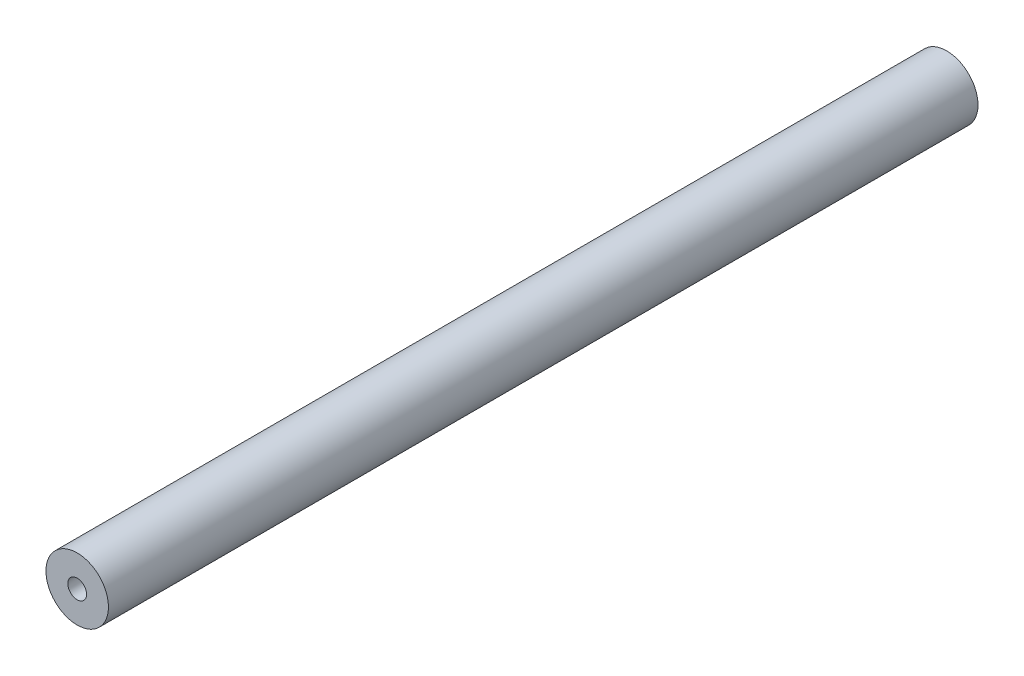
from build123d import *

# Parameters (mm, degrees)
SKETCH1_R           = 31.75
SKETCH1_R_2         = 9.525
BOSS_EXTRUDE1_DEPTH = 883.412


with BuildPart() as part:
    # Sketch1 → Boss-Extrude1 (new body)
    with BuildSketch(Plane.XY):
        Circle(SKETCH1_R)
        Circle(SKETCH1_R_2, mode=Mode.SUBTRACT)
    extrude(amount=BOSS_EXTRUDE1_DEPTH)


solid = part.part
